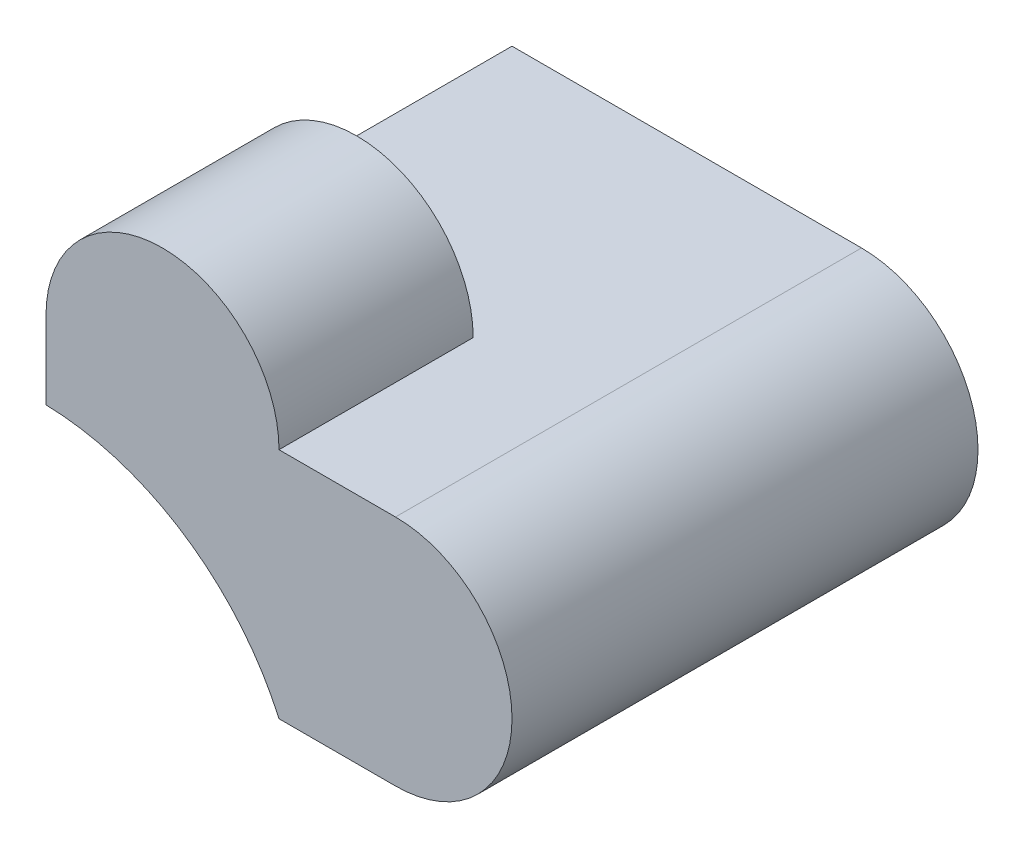
from build123d import *

# Parameters (mm, degrees)
SKETCH1_W               = 6
SKETCH1_H               = 6
BOSS_EXTRUDE1_DEPTH     = 5
CUT_EXTRUDE1_DEPTH      = 10
CUT_EXTRUDE2_DEPTH      = 1
CUT_EXTRUDE2_DEPTH_BACK = 2.5
SKETCH4_W               = 3.5
SKETCH4_H               = 1.5
CUT_EXTRUDE3_DEPTH      = 12.5


with BuildPart() as part:
    # Sketch1 → Boss-Extrude1 (new body)
    with BuildSketch(Plane(origin=(0, 0, 0), x_dir=(1, 0, 0), z_dir=(0, 1, 0))):
        Rectangle(SKETCH1_W, SKETCH1_H)
    extrude(amount=BOSS_EXTRUDE1_DEPTH)

    # Sketch2 → Cut-Extrude1 (cut)
    with BuildSketch(Plane.XY.offset(3)):
        with BuildLine():
            ThreePointArc((-3, 3), (-1.5, 4.5), (0, 3))
            Line((0, 3), (1.5, 3))
            ThreePointArc((1.5, 3), (2.560660172, 2.560660172), (3, 1.5))
            Line((3, 1.5), (3, 5))
            Line((3, 5), (-3, 5))
            Line((-3, 5), (-3, 3))
        make_face()
        with BuildLine():
            Line((3, 0), (3, 1.5))
            ThreePointArc((3, 1.5), (2.560660172, 0.439339828), (1.5, 0))
            Line((1.5, 0), (3, 0))
        make_face()
    extrude(amount=-CUT_EXTRUDE1_DEPTH, mode=Mode.SUBTRACT)

    # Sketch3 → Cut-Extrude2 (cut, two sides)
    with BuildSketch(Plane.XY.offset(3)) as cut_extrude2_sk:
        with BuildLine():
            Line((-3, 2), (-3, 0))
            Line((-3, 0), (0, 0))
            ThreePointArc((0, 0), (-1.210432595, 1.434351108), (-3, 2))
        make_face()
    extrude(amount=CUT_EXTRUDE2_DEPTH, mode=Mode.SUBTRACT)
    extrude(cut_extrude2_sk.sketch, amount=-CUT_EXTRUDE2_DEPTH_BACK, mode=Mode.SUBTRACT)

    # Sketch4 → Cut-Extrude3 (cut)
    with BuildSketch(Plane.ZY.offset(3)):
        with Locations((-1.25, 3.75)):
            Rectangle(SKETCH4_W, SKETCH4_H)
    extrude(amount=-CUT_EXTRUDE3_DEPTH, mode=Mode.SUBTRACT)


solid = part.part
